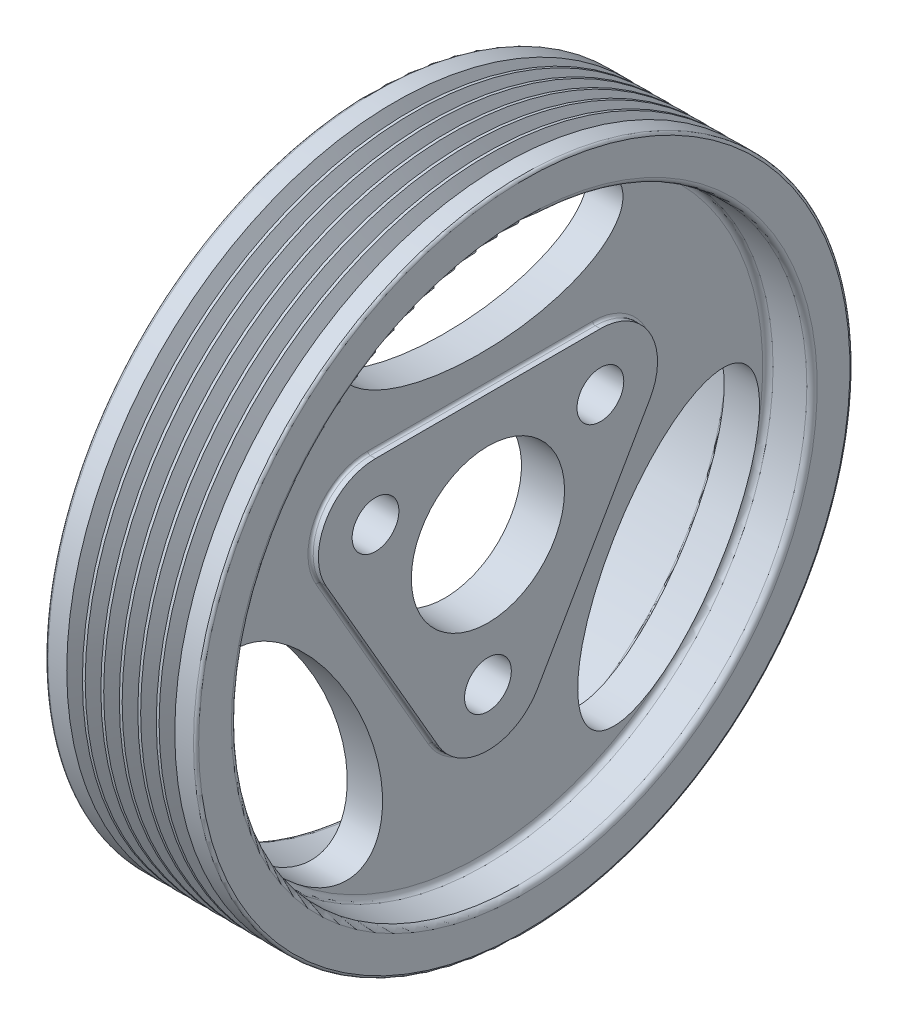
from build123d import *
from build123d.topology import SkipClean

# Parameters (mm, degrees)
FILLET_1_R               = 1
FILLET_2_R               = 0.5
CUT_EXTRUDE_1_DEPTH      = 91.678387723
CUT_EXTRUDE_1_DEPTH_BACK = 91.678387723
SKETCH_3_R               = 4.5
SKETCH_3_RX              = 27.5
SKETCH_3_RY              = 12.5
SKETCH_4_R               = 4.5
SKETCH_4_R_2             = 14.75
EXTRUDE_1_DEPTH          = 1.5
FILLET_3_R               = 0.5
SKETCH_5_R               = 8
CUT_EXTRUDE_2_DEPTH      = 1


with BuildPart() as part:
    # Эскиз1 → Повернуть1 (revolve)
    with BuildSketch(Plane.XY, mode=Mode.PRIVATE) as revolve_1_sk:
        Polygon((13.7, 14.75), (20.5, 14.75), (20.5, 55.4), (29, 55.4), (29, 63.2), (0, 63.2), (0, 55.4), (13.7, 55.4), align=None)
    revolve(revolve_1_sk.sketch.rotate(Axis((-584.151441429, 0, 0), (1, 0, 0)), 90), axis=Axis((-584.151441429, 0, 0), (1, 0, 0)))

    # Скругление1
    fillet_1_edges = [part.edges().sort_by_distance(p)[0] for p in [
        (13.7, 0, -55.4),
        (0, 0, -55.4),
        (29, 0, -55.4),
        (20.5, 0, -55.4),
    ]]
    fillet(fillet_1_edges, radius=FILLET_1_R)

    # Скругление2
    fillet_2_edges = [part.edges().sort_by_distance(p)[0] for p in [
        (0, 0, -63.2),
        (29, 0, -63.2),
    ]]
    fillet(fillet_2_edges, radius=FILLET_2_R)


with BuildPart() as body_2:
    # Эскиз2 → Повернуть2 (revolve)
    with BuildSketch(Plane(origin=(0, 0, 0), x_dir=(1, 0, 0), z_dir=(0, 1, 0)), mode=Mode.PRIVATE) as revolve_2_sk:
        Polygon((3.82852215, 63.7), (5.607101792, 60.424263798), (7.385681433, 63.7), (9.164261075, 60.424263798), (10.942840717, 63.7), (12.721420358, 60.424263798), (14.5, 63.7), (16.278579642, 60.424263798), (18.057159283, 63.7), (19.835738925, 60.424263798), (21.614318567, 63.7), (23.392898208, 60.424263798), (25.17147785, 63.7), (25.17147785, 68.7), (3.82852215, 68.7), align=None)
    revolve(revolve_2_sk.sketch.rotate(Axis((-584.151441429, 0, 0), (1, 0, 0)), 180), axis=Axis((-584.151441429, 0, 0), (1, 0, 0)))


with BuildPart() as part_1:
    add(part.part)

    # Combine 1: cut body 2
    add(body_2.part, mode=Mode.SUBTRACT)

    # Эскиз3 → Вырез-Вытянуть1 (cut, two sides: drawn at the far end of the back side and taken through both)
    with BuildSketch(Plane.ZY.offset(-13.7).offset(-CUT_EXTRUDE_1_DEPTH_BACK)):
        with Locations((0, -25)):
            Circle(SKETCH_3_R)
        with Locations((-21.650635095, 12.5)):
            Circle(SKETCH_3_R)
        with Locations((21.650635095, 12.5)):
            Circle(SKETCH_3_R)
        with Locations((0, 41.9)):
            Ellipse(SKETCH_3_RX, SKETCH_3_RY)
        with Locations(Location((36.286464419, -20.95), (0, 0, -120))):
            Ellipse(SKETCH_3_RX, SKETCH_3_RY)
        with Locations(Location((-36.286464419, -20.95), (0, 0, 120))):
            Ellipse(SKETCH_3_RX, SKETCH_3_RY)
    extrude(amount=CUT_EXTRUDE_1_DEPTH + CUT_EXTRUDE_1_DEPTH_BACK, mode=Mode.SUBTRACT)

    # Эскиз4 → Бобышка-Вытянуть1 (add)
    with SkipClean():  # the faces are left unmerged after this step: merging them gives an invalid solid
        with BuildSketch(Plane(origin=(20.5, 0, 0), x_dir=(0, 0, -1), z_dir=(1, 0, 0))):
            with BuildLine():
                Line((-21.650635095, 23.5), (21.650635095, 23.5))
                ThreePointArc((21.650635095, 23.5), (31.176914536, 18), (31.176914536, 7))
                Line((31.176914536, 7), (9.526279442, -30.5))
                ThreePointArc((9.526279442, -30.5), (0, -36), (-9.526279442, -30.5))
                Line((-9.526279442, -30.5), (-31.176914536, 7))
                ThreePointArc((-31.176914536, 7), (-31.176914536, 18), (-21.650635095, 23.5))
            make_face()
            with Locations((21.650635095, 12.5)):
                Circle(SKETCH_4_R, mode=Mode.SUBTRACT)
            with Locations((0, -25)):
                Circle(SKETCH_4_R, mode=Mode.SUBTRACT)
            with Locations((-21.650635095, 12.5)):
                Circle(SKETCH_4_R, mode=Mode.SUBTRACT)
            with Locations(Location((0, 0, 0), (0, 0, 180))):
                Circle(SKETCH_4_R_2, mode=Mode.SUBTRACT)
        extrude(amount=EXTRUDE_1_DEPTH)

    # Скругление3
    fillet_3_edges = [part_1.edges().sort_by_distance(p)[0] for p in [
        (20.5, 18, 31.176914536),
        (20.5, -11.75, 20.351596989),
        (20.5, -36, 0),
        (20.5, -11.75, -20.351596989),
        (20.5, 18, -31.176914536),
        (20.5, 23.5, 0),
    ]]
    fillet(fillet_3_edges, radius=FILLET_3_R)

    # Эскиз5 → Вырез-Вытянуть2 (cut)
    with BuildSketch(Plane.ZY.offset(-13.7)):
        with Locations((-21.650635095, 12.5)):
            Circle(SKETCH_5_R)
        with Locations((21.650635095, 12.5)):
            Circle(SKETCH_5_R)
        with Locations((0, -25)):
            Circle(SKETCH_5_R)
    extrude(amount=-CUT_EXTRUDE_2_DEPTH, mode=Mode.SUBTRACT)


solid = part_1.part
